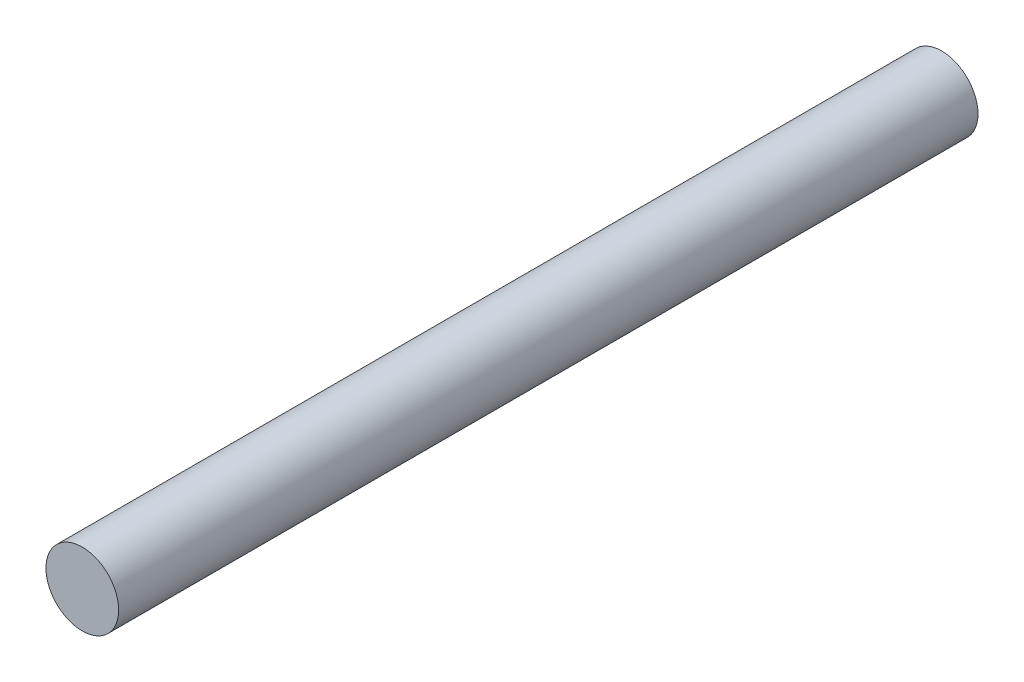
from build123d import *

# Parameters (mm, degrees)
SKETCH1_R           = 5.5
BOSS_EXTRUDE1_DEPTH = 130


with BuildPart() as part:
    # Sketch1 → Boss-Extrude1 (new body)
    with BuildSketch(Plane.XY):
        with Locations((-2.678530236, -4.218685121)):
            Circle(SKETCH1_R)
    extrude(amount=BOSS_EXTRUDE1_DEPTH)


solid = part.part
